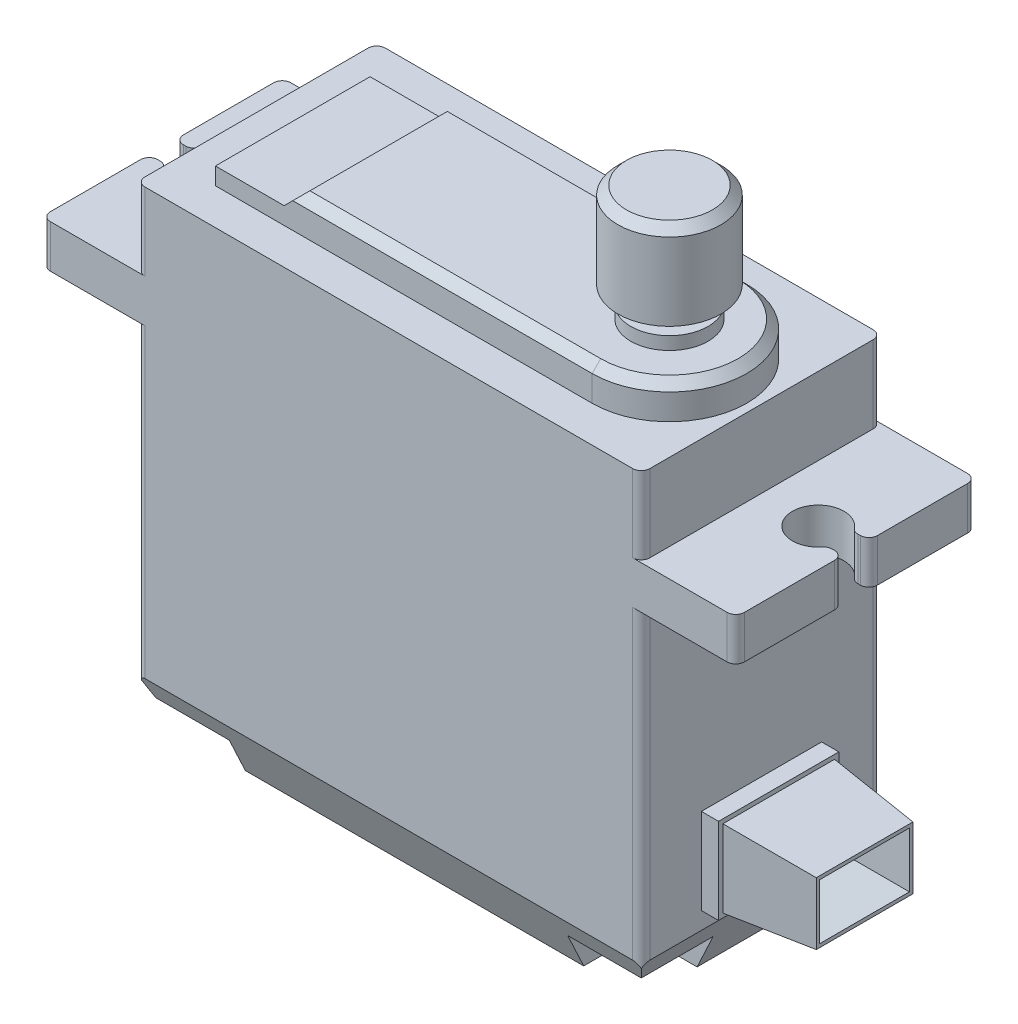
from build123d import *

# Parameters (mm, degrees)
CROQUIS1_W              = 29.4
CROQUIS1_H              = 28
SALIENTE_EXTRUIR1_DEPTH = 7
CROQUIS2_W              = 5.5
CROQUIS2_H              = 2.5
SALIENTE_EXTRUIR2_DEPTH = 14
CORTAR_EXTRUIR1_DEPTH   = 2.5
CHAFL_N1_SIZE           = 1.5
CHAFL_N1_SIZE2          = 3.216760381
CORTAR_EXTRUIR2_DEPTH   = 2
SALIENTE_EXTRUIR4_DEPTH = 2
CORTAR_EXTRUIR3_START   = -9
CORTAR_EXTRUIR3_DEPTH   = 9
CROQUIS10_R             = 2.25
SALIENTE_EXTRUIR5_DEPTH = 0.75
CROQUIS11_R             = 0.75
SALIENTE_EXTRUIR6_DEPTH = 1
CROQUIS12_R             = 3
SALIENTE_EXTRUIR7_DEPTH = 5
CROQUIS14_W             = 7
CROQUIS14_H             = 5
SALIENTE_EXTRUIR8_DEPTH = 1
CROQUIS15_W             = 6.5
CROQUIS15_H             = 4.5
SALIENTE_EXTRUIR9_DEPTH = 5
SALIENTE_EXTRUIR9_TAPER = 5
VACIADO2_T              = -0.2
CHAFL_N2_SIZE           = 0.5
FILLET1_R               = 0.5


with BuildPart() as part:
    # Croquis1 → Saliente-Extruir1 (new body, symmetric)
    with BuildSketch(Plane.XY):
        Rectangle(CROQUIS1_W, CROQUIS1_H)
    extrude(amount=SALIENTE_EXTRUIR1_DEPTH, both=True)

    # Croquis2 → Saliente-Extruir2 (add)
    with BuildSketch(Plane.XY.offset(7)):
        with Locations((-17.45, 8.25)):
            Rectangle(CROQUIS2_W, CROQUIS2_H)
        with Locations((17.45, 8.25)):
            Rectangle(CROQUIS2_W, CROQUIS2_H)
    extrude(amount=-SALIENTE_EXTRUIR2_DEPTH)

    # Croquis4 → Cortar-Extruir1 (cut)
    with BuildSketch(Plane(origin=(0, 9.5, 0), x_dir=(1, 0, 0), z_dir=(0, 1, 0))):
        with BuildLine():
            Line((-20.2, 0.75), (-19.299038106, 0.75))
            ThreePointArc((-19.299038106, 0.75), (-16.5, 0), (-19.299038106, -0.75))
            Line((-19.299038106, -0.75), (-20.2, -0.75))
            Line((-20.2, -0.75), (-20.2, 0.75))
        make_face()
        with BuildLine():
            Line((20.2, -0.75), (20.2, 0.75))
            Line((20.2, 0.75), (19.299038106, 0.75))
            ThreePointArc((19.299038106, 0.75), (16.5, 0), (19.299038106, -0.75))
            Line((19.299038106, -0.75), (20.2, -0.75))
        make_face()
    extrude(amount=-CORTAR_EXTRUIR1_DEPTH, mode=Mode.SUBTRACT)

    # Chaflán1
    chafl_n1_edges = [part.edges().sort_by_distance(p)[0] for p in [
        (0, -14, -7),
        (0, -14, 7),
        (-14.7, -14, 0),
        (14.7, -14, 0),
    ]]
    chafl_n1_side = [part.faces().sort_by_distance(p)[0] for p in [
        (0, -14, 0),
    ]]
    chamfer(chafl_n1_edges, length=CHAFL_N1_SIZE, length2=CHAFL_N1_SIZE2, reference=chafl_n1_side[0])

    # Croquis5 → Cortar-Extruir2 (cut)
    with BuildSketch(Plane.XZ.offset(14)):
        with BuildLine():
            Line((-14.7, 2.25), (-11.85, 2.25))
            ThreePointArc((-11.85, 2.25), (-10.435786438, 2.835786438), (-9.85, 4.25))
            Line((-9.85, 4.25), (-9.85, 7))
            Line((-9.85, 7), (-14.7, 7))
            Line((-14.7, 7), (-14.7, 2.25))
        make_face()
        with BuildLine():
            Line((-14.7, -7), (-14.7, -2.25))
            Line((-14.7, -2.25), (-11.85, -2.25))
            ThreePointArc((-11.85, -2.25), (-10.435786438, -2.835786438), (-9.85, -4.25))
            Line((-9.85, -4.25), (-9.85, -7))
            Line((-9.85, -7), (-14.7, -7))
        make_face()
        with BuildLine():
            Line((14.7, -2.25), (11.85, -2.25))
            ThreePointArc((11.85, -2.25), (10.435786438, -2.835786438), (9.85, -4.25))
            Line((9.85, -4.25), (9.85, -7))
            Line((9.85, -7), (14.7, -7))
            Line((14.7, -7), (14.7, -2.25))
        make_face()
        with BuildLine():
            Line((14.7, 7), (14.7, 2.25))
            Line((14.7, 2.25), (11.85, 2.25))
            ThreePointArc((11.85, 2.25), (10.435786438, 2.835786438), (9.85, 4.25))
            Line((9.85, 4.25), (9.85, 7))
            Line((9.85, 7), (14.7, 7))
        make_face()
    extrude(amount=-CORTAR_EXTRUIR2_DEPTH, mode=Mode.SUBTRACT)

    # Croquis6 → Saliente-Extruir4 (add)
    with BuildSketch(Plane(origin=(0, 14, 0), x_dir=(1, 0, 0), z_dir=(0, 1, 0))):
        with BuildLine():
            Line((9.73, 4.11), (-12.2, 4.11))
            Line((-12.2, 4.11), (-12.2, -4.89))
            Line((-12.2, -4.89), (9.73, -4.89))
            ThreePointArc((9.73, -4.89), (14.23, -0.39), (9.73, 4.11))
        make_face()
    extrude(amount=SALIENTE_EXTRUIR4_DEPTH)

    # Croquis9 → Cortar-Extruir3 (cut)
    with BuildSketch(Plane.XY.offset(4.89).offset(CORTAR_EXTRUIR3_START)):
        Polygon((-12.2, 16), (-12.2, 15), (-8.2, 15), (-7.2, 16), align=None)
    extrude(amount=CORTAR_EXTRUIR3_DEPTH, mode=Mode.SUBTRACT)

    # Croquis10 → Saliente-Extruir5 (add)
    with BuildSketch(Plane(origin=(0, 16, 0), x_dir=(1, 0, 0), z_dir=(0, 1, 0))):
        with Locations((9.73, -0.39)):
            Circle(CROQUIS10_R)
    extrude(amount=SALIENTE_EXTRUIR5_DEPTH)

    # Croquis11 → Saliente-Extruir6 (add)
    with BuildSketch(Plane(origin=(0, 16.75, 0), x_dir=(1, 0, 0), z_dir=(0, 1, 0))):
        with Locations((9.73, -0.39)):
            Circle(CROQUIS11_R)
    extrude(amount=SALIENTE_EXTRUIR6_DEPTH)

    # Croquis12 → Saliente-Extruir7 (add)
    with BuildSketch(Plane(origin=(0, 17.75, 0), x_dir=(1, 0, 0), z_dir=(0, 1, 0))):
        with Locations((9.73, -0.39)):
            Circle(CROQUIS12_R)
    extrude(amount=SALIENTE_EXTRUIR7_DEPTH)

    # Croquis14 → Saliente-Extruir8 (add)
    with BuildSketch(Plane(origin=(14.7, 0, 0), x_dir=(0, 0, -1), z_dir=(1, 0, 0))):
        with Locations((0, -7.283239619)):
            Rectangle(CROQUIS14_W, CROQUIS14_H)
    extrude(amount=SALIENTE_EXTRUIR8_DEPTH)

    # Chaflán2
    chafl_n2_edges = [part.edges().sort_by_distance(p)[0] for p in [
        (14.23, 16, 0.39),
        (1.265, 16, -4.11),
        (1.265, 16, 4.89),
        (6.73, 22.75, 0.39),
    ]]
    chamfer(chafl_n2_edges, length=CHAFL_N2_SIZE)

    # Fillet1
    fillet1_edges = [part.edges().sort_by_distance(p)[0] for p in [
        (14.7, 11.75, -7),
        (14.7, 11.75, 7),
        (14.7, -1.89161981, 7),
        (14.7, -1.89161981, -7),
        (20.2, 8.25, -7),
        (19.299038106, 8.25, 0.75),
        (19.299038106, 8.25, -0.75),
        (20.2, 8.25, -0.75),
        (20.2, 8.25, 0.75),
        (20.2, 8.25, 7),
        (-19.299038106, 8.25, -0.75),
        (-20.2, 8.25, 7),
        (-14.7, 11.75, -7),
        (-14.7, 11.75, 7),
        (-14.7, -1.89161981, 7),
        (-19.299038106, 8.25, 0.75),
        (-20.2, 8.25, 0.75),
        (-20.2, 8.25, -0.75),
        (-20.2, 8.25, -7),
        (-14.7, -1.89161981, -7),
    ]]
    fillet(fillet1_edges, radius=FILLET1_R)


with BuildPart() as body_2:
    # Croquis15 → Saliente-Extruir9 (new body)
    with BuildSketch(Plane(origin=(15.7, 0, 0), x_dir=(0, 0, -1), z_dir=(1, 0, 0))):
        with Locations((0, -7.283239619)):
            Rectangle(CROQUIS15_W, CROQUIS15_H)
    extrude(amount=SALIENTE_EXTRUIR9_DEPTH, taper=SALIENTE_EXTRUIR9_TAPER)

    # Vaciado2
    vaciado2_openings = [body_2.faces().sort_by_distance(p)[0] for p in [
        (20.7, -7.283239619, 0),
    ]]
    offset(amount=VACIADO2_T, openings=vaciado2_openings, kind=Kind.INTERSECTION)


solid = Compound([part.part, body_2.part])
